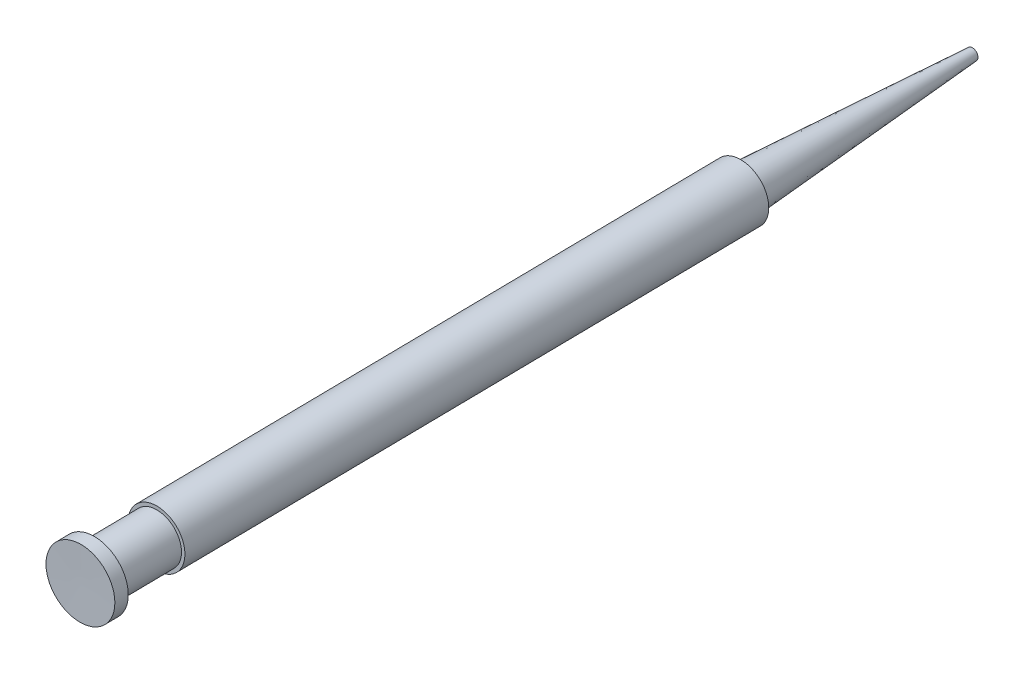
from build123d import *


with BuildPart() as part:
    # Sketch2 → Revolve4 (revolve)
    with BuildSketch(Plane(origin=(0, 0, 0), x_dir=(1, 0, 0), z_dir=(0, 1, 0))):
        Polygon((24.882765403, 17.005709542), (25.875695003, -55.987537343), (29.626041942, -55.987537343), (29.605639279, -54.487676105), (28.580544449, -54.487676105), (28.485332021, -47.488323664), (28.860366715, -47.488323664), (27.97160056, 17.8475545), (27.163610623, 17.8475545), (25.134414226, 43.778408192), (24.518575479, 43.778408192), align=None)
    revolve(axis=Axis((24.882765403, 0, -17.005709542), (0.013601775, 0, 0.999907492)))


solid = part.part
